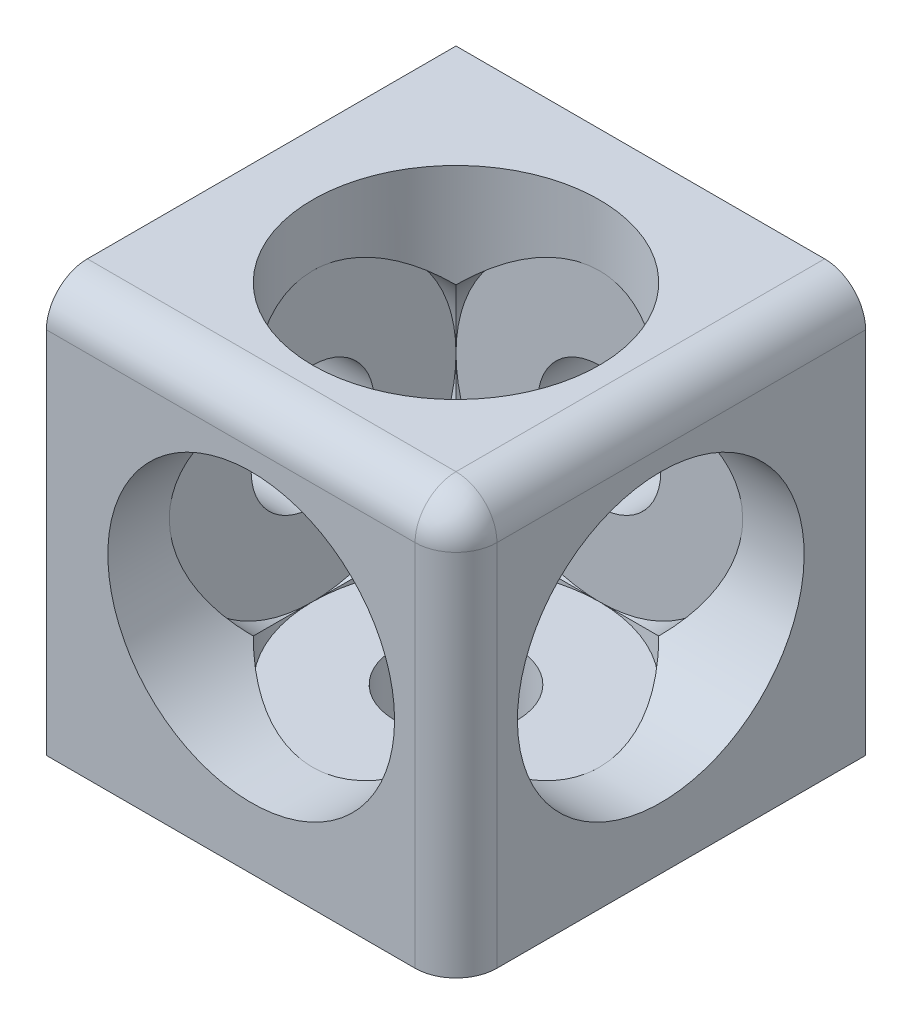
from build123d import *

# Parameters (mm, degrees)
ESQUISSE1_W             = 20
ESQUISSE1_H             = 20
BOSS_EXTRU_1_DEPTH      = 20
CONG_1_R                = 2
ESQUISSE2_R             = 3
ENL_V_MAT_EXTRU_1_DEPTH = 21
ESQUISSE3_R             = 3
ENL_V_MAT_EXTRU_2_DEPTH = 21
ESQUISSE4_R             = 3
ENL_V_MAT_EXTRU_3_DEPTH = 21
ESQUISSE5_R             = 7
ENL_V_MAT_EXTRU_4_DEPTH = 17
ESQUISSE6_R             = 7
ENL_V_MAT_EXTRU_5_DEPTH = 17
ESQUISSE7_R             = 7
ENL_V_MAT_EXTRU_6_DEPTH = 17


with BuildPart() as part:
    # Esquisse1 → Boss.-Extru.1 (new body)
    with BuildSketch(Plane.XY):
        with Locations((-10, 10)):
            Rectangle(ESQUISSE1_W, ESQUISSE1_H)
    extrude(amount=BOSS_EXTRU_1_DEPTH)

    # Congé1
    cong_1_edges = [part.edges().sort_by_distance(p)[0] for p in [
        (0, 10, 20),
        (-10, 20, 20),
        (0, 20, 10),
    ]]
    fillet(cong_1_edges, radius=CONG_1_R)

    # Esquisse2 → Enlèv. mat.-Extru.1 (cut, through all)
    with BuildSketch(Plane.XY.offset(20)):
        with Locations((-10, 10)):
            Circle(ESQUISSE2_R)
    extrude(amount=-ENL_V_MAT_EXTRU_1_DEPTH, mode=Mode.SUBTRACT)

    # Esquisse3 → Enlèv. mat.-Extru.2 (cut, through all)
    with BuildSketch(Plane(origin=(0, 0, 0), x_dir=(0, 0, -1), z_dir=(1, 0, 0))):
        with Locations(Location((-10, 10, 0), (0, 0, 90))):  # turned: the seam where the file's is
            Circle(ESQUISSE3_R)
    extrude(amount=-ENL_V_MAT_EXTRU_2_DEPTH, mode=Mode.SUBTRACT)

    # Esquisse4 → Enlèv. mat.-Extru.3 (cut, through all)
    with BuildSketch(Plane(origin=(0, 20, 0), x_dir=(-1, 0, 0), z_dir=(0, 1, 0))):
        with Locations(Location((10, 10, 0), (0, 0, 90))):  # turned: the seam where the file's is
            Circle(ESQUISSE4_R)
    extrude(amount=-ENL_V_MAT_EXTRU_3_DEPTH, mode=Mode.SUBTRACT)

    # Esquisse5 → Enlèv. mat.-Extru.4 (cut)
    with BuildSketch(Plane.XY.offset(20)):
        with Locations((-10, 10)):
            Circle(ESQUISSE5_R)
    extrude(amount=-ENL_V_MAT_EXTRU_4_DEPTH, mode=Mode.SUBTRACT)

    # Esquisse6 → Enlèv. mat.-Extru.5 (cut)
    with BuildSketch(Plane(origin=(0, 0, 0), x_dir=(0, 0, -1), z_dir=(1, 0, 0))):
        with Locations(Location((-10, 10, 0), (0, 0, 90))):  # turned: the seam where the file's is
            Circle(ESQUISSE6_R)
    extrude(amount=-ENL_V_MAT_EXTRU_5_DEPTH, mode=Mode.SUBTRACT)

    # Esquisse7 → Enlèv. mat.-Extru.6 (cut)
    with BuildSketch(Plane(origin=(0, 20, 0), x_dir=(1, 0, 0), z_dir=(0, 1, 0))):
        with Locations(Location((-10, -10, 0), (0, 0, 270))):  # turned: the seam where the file's is
            Circle(ESQUISSE7_R)
    extrude(amount=-ENL_V_MAT_EXTRU_6_DEPTH, mode=Mode.SUBTRACT)


solid = part.part
